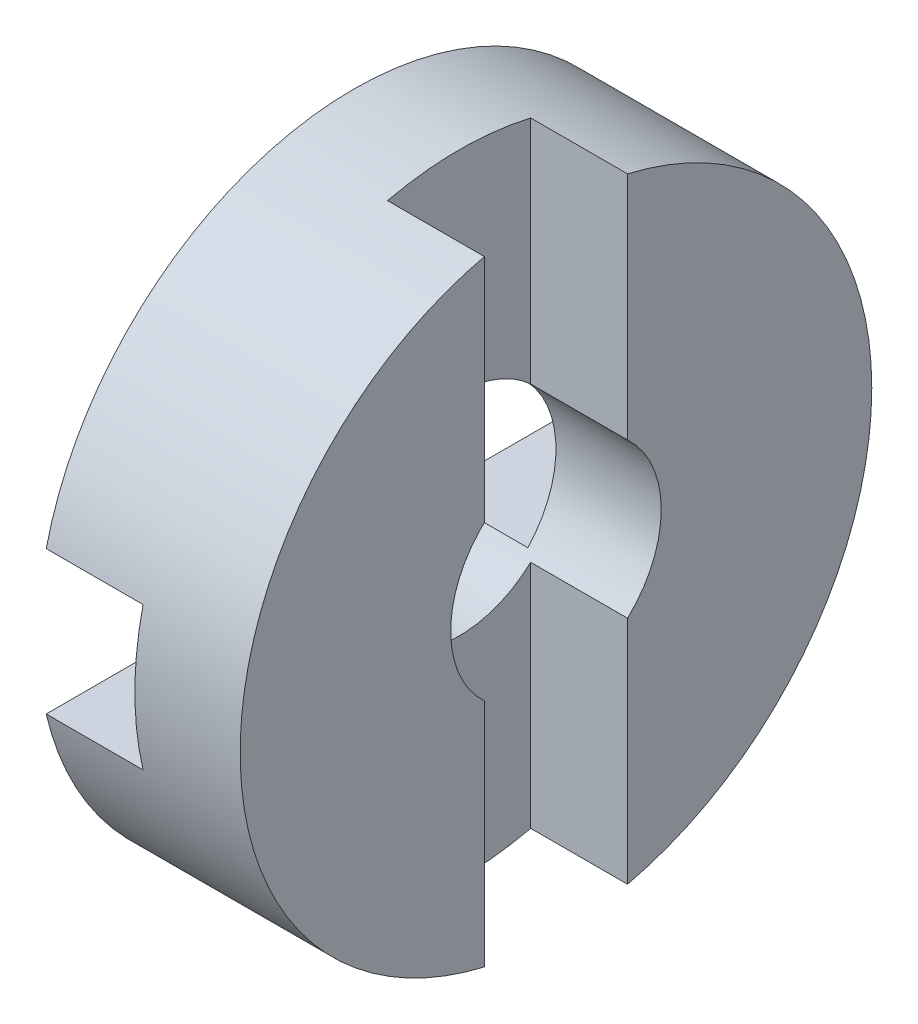
from build123d import *

# Parameters (mm, degrees)
SKETCH1_W               = 4.8
SKETCH1_H               = 5
CUT_EXTRUDE1_DEPTH      = 7.5
CUT_EXTRUDE1_DEPTH_BACK = 7.5
SKETCH2_W               = 2.3
SKETCH2_H               = 3.4
CUT_EXTRUDE2_DEPTH      = 7.5
CUT_EXTRUDE2_DEPTH_BACK = 7.5
SKETCH3_W               = 2.3
SKETCH3_H               = 3.4


with BuildPart() as part:
    # Sketch1 → Revolve1 (revolve)
    with BuildSketch(Plane.XY):
        with Locations((2.4, 5)):
            Rectangle(SKETCH1_W, SKETCH1_H)
    revolve(axis=Axis((4.8, 0, 0), (-1, 0, 0)))

    # Sketch2 → Cut-Extrude1 (cut, two sides: drawn at the far end of the back side and taken through both)
    with BuildSketch(Plane.XY.offset(-CUT_EXTRUDE1_DEPTH_BACK)):
        with Locations((1.15, 0)):
            Rectangle(SKETCH2_W, SKETCH2_H)
    extrude(amount=CUT_EXTRUDE1_DEPTH + CUT_EXTRUDE1_DEPTH_BACK, mode=Mode.SUBTRACT)

    # Sketch3 → Cut-Extrude2 (cut, two sides: drawn at the far end of the back side and taken through both)
    with BuildSketch(Plane(origin=(0, 0, 0), x_dir=(-1, 0, 0), z_dir=(0, 1, 0)).offset(-CUT_EXTRUDE2_DEPTH_BACK)):
        with Locations((-3.65, 0)):
            Rectangle(SKETCH3_W, SKETCH3_H)
    extrude(amount=CUT_EXTRUDE2_DEPTH + CUT_EXTRUDE2_DEPTH_BACK, mode=Mode.SUBTRACT)


solid = part.part
